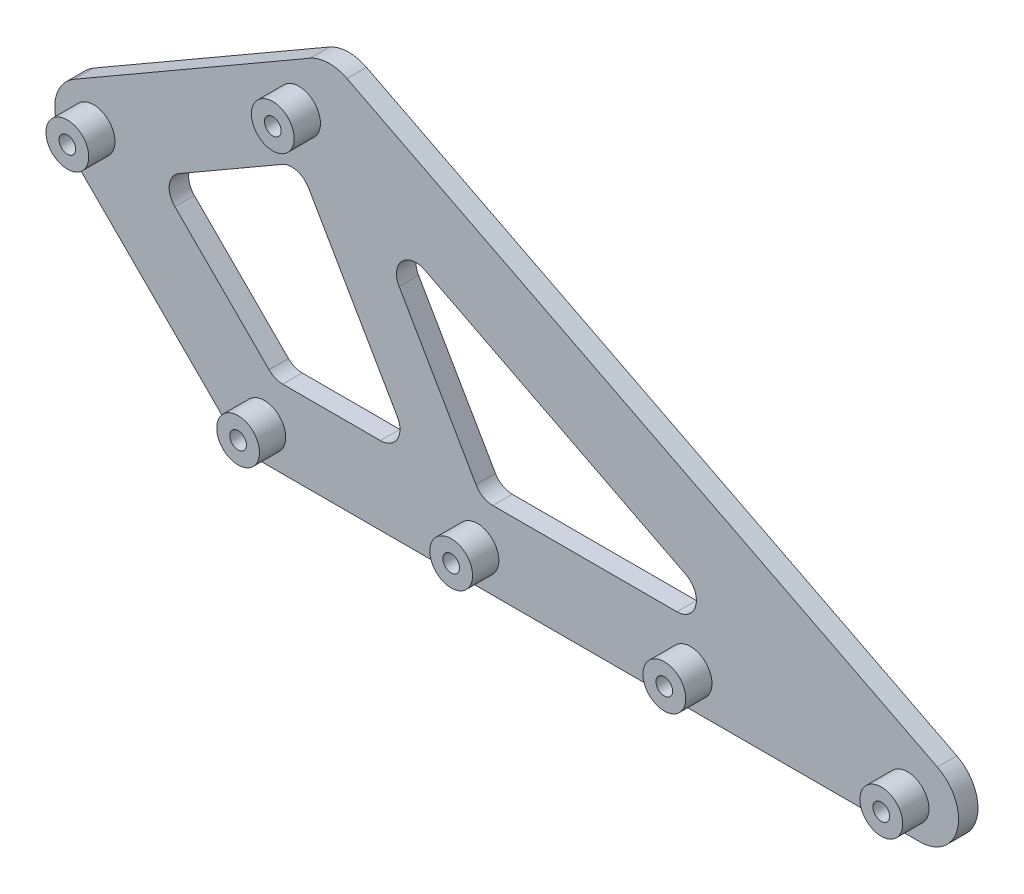
from build123d import *

# Parameters (mm, degrees)
BOSS_EXTRUDE1_DEPTH = 5
BOSS_EXTRUDE2_DEPTH = 5
FILLET1_R           = 5
SKETCH3_R           = 5.5
SKETCH3_R_2         = 2.15
BOSS_EXTRUDE3_DEPTH = 6.75
SKETCH4_R           = 2.15
CUT_EXTRUDE1_DEPTH  = 6


with BuildPart() as part:
    # Sketch1 → Boss-Extrude1 (new body)
    with BuildSketch(Plane.XY):
        with BuildLine():
            Line((-35.355339059, 49.497474683), (-26.140144074, 40.282279698))
            Line((-26.140144074, 40.282279698), (18.49094778, 66.050052594))
            Line((18.49094778, 66.050052594), (13.651828996, 68.518195913))
            ThreePointArc((13.651828996, 68.518195913), (8.198744915, 77.166678081), (13.195371394, 86.086660909))
            Line((13.195371394, 86.086660909), (-47.426406871, 51.086660909))
            ThreePointArc((-47.426406871, 51.086660909), (-41.121144949, 52.340855485), (-35.355339059, 49.497474683))
        make_face()
        with BuildLine():
            Line((18.49094778, 66.050052594), (128.384429361, 10))
            Line((128.384429361, 10), (170, 10))
            ThreePointArc((170, 10), (172.336438573, 9.723222449), (174.543542397, 8.908210959))
            Line((174.543542397, 8.908210959), (22.738913791, 86.33461783))
            ThreePointArc((22.738913791, 86.33461783), (28.191997872, 77.686135661), (23.195371394, 68.766152833))
            Line((23.195371394, 68.766152833), (18.49094778, 66.050052594))
        make_face()
        with BuildLine():
            Line((128.384429361, 10), (4.142135624, 10))
            Line((4.142135624, 10), (7.071067812, 7.071067812))
            ThreePointArc((7.071067812, 7.071067812), (9.238795325, -3.826834324), (0, -10))
            Line((0, -10), (170, -10))
            ThreePointArc((170, -10), (167.663561427, -9.723222449), (165.456457603, -8.908210959))
            Line((165.456457603, -8.908210959), (128.384429361, 10))
        make_face()
        with BuildLine():
            ThreePointArc((-7.071067812, -7.071067812), (-9.238795325, 3.826834324), (0, 10))
            Line((0, 10), (4.142135624, 10))
            Line((4.142135624, 10), (-26.140144074, 40.282279698))
            Line((-26.140144074, 40.282279698), (-37.426406871, 33.766152833))
            ThreePointArc((-37.426406871, 33.766152833), (-43.731668793, 32.511958257), (-49.497474683, 35.355339059))
            Line((-49.497474683, 35.355339059), (-7.071067812, -7.071067812))
        make_face()
        with BuildLine():
            Line((170, 10), (128.384429361, 10))
            Line((128.384429361, 10), (165.456457603, -8.908210959))
            ThreePointArc((165.456457603, -8.908210959), (167.663561427, -9.723222449), (170, -10))
            ThreePointArc((170, -10), (179.723222449, -2.336438573), (174.543542397, 8.908210959))
            ThreePointArc((174.543542397, 8.908210959), (172.336438573, 9.723222449), (170, 10))
        make_face()
        with BuildLine():
            Line((13.651828996, 68.518195913), (18.49094778, 66.050052594))
            Line((18.49094778, 66.050052594), (23.195371394, 68.766152833))
            ThreePointArc((23.195371394, 68.766152833), (28.191997872, 77.686135661), (22.738913791, 86.33461783))
            ThreePointArc((22.738913791, 86.33461783), (17.935642604, 87.42303335), (13.195371394, 86.086660909))
            ThreePointArc((13.195371394, 86.086660909), (8.198744915, 77.166678081), (13.651828996, 68.518195913))
        make_face()
        with BuildLine():
            Line((-37.426406871, 33.766152833), (-26.140144074, 40.282279698))
            Line((-26.140144074, 40.282279698), (-35.355339059, 49.497474683))
            ThreePointArc((-35.355339059, 49.497474683), (-41.121144949, 52.340855485), (-47.426406871, 51.086660909))
            ThreePointArc((-47.426406871, 51.086660909), (-52.340855485, 43.731668793), (-49.497474683, 35.355339059))
            ThreePointArc((-49.497474683, 35.355339059), (-43.731668793, 32.511958257), (-37.426406871, 33.766152833))
        make_face()
        with BuildLine():
            Line((4.142135624, 10), (0, 10))
            ThreePointArc((0, 10), (-9.238795325, 3.826834324), (-7.071067812, -7.071067812))
            ThreePointArc((-7.071067812, -7.071067812), (-3.826834324, -9.238795325), (0, -10))
            ThreePointArc((0, -10), (9.238795325, -3.826834324), (7.071067812, 7.071067812))
            Line((7.071067812, 7.071067812), (4.142135624, 10))
        make_face()
    extrude(amount=BOSS_EXTRUDE1_DEPTH)

    # Sketch2 → Boss-Extrude2 (add, through all)
    with BuildSketch(Plane.XY.offset(5)):
        Polygon((18.49094778, 66.050052594), (10.366771374, 61.359557158), (40.019225525, 10), (57.3397336, 10), (27.687279449, 61.359557158), align=None)
    extrude(amount=-BOSS_EXTRUDE2_DEPTH)

    # Fillet1
    fillet1_edges = [part.edges().sort_by_distance(p)[0] for p in [
        (-26.140144074, 40.282279698, 2.5),
        (4.142135624, 10, 2.5),
        (128.384429361, 10, 2.5),
        (27.687279449, 61.359557158, 2.5),
        (57.3397336, 10, 2.5),
        (40.019225525, 10, 2.5),
        (10.366771374, 61.359557158, 2.5),
    ]]
    fillet(fillet1_edges, radius=FILLET1_R)

    # Sketch3 → Boss-Extrude3 (add)
    with BuildSketch(Plane.XY.offset(5)):
        with Locations((-42.426406871, 42.426406871)):
            Circle(SKETCH3_R)
        with Locations((-42.426406871, 42.426406871)):
            Circle(SKETCH3_R_2, mode=Mode.SUBTRACT)
        with Locations((1.48492424, -1.48492424)):
            Circle(SKETCH3_R)
        with Locations((1.48492424, -1.48492424)):
            Circle(SKETCH3_R_2, mode=Mode.SUBTRACT)
        with Locations((56.28492424, -1.48492424)):
            Circle(SKETCH3_R)
        with Locations((56.28492424, -1.48492424)):
            Circle(SKETCH3_R_2, mode=Mode.SUBTRACT)
        with Locations((111.08492424, -1.48492424)):
            Circle(SKETCH3_R)
        with Locations((111.08492424, -1.48492424)):
            Circle(SKETCH3_R_2, mode=Mode.SUBTRACT)
        with Locations((166.88492424, -1.48492424)):
            Circle(SKETCH3_R)
        with Locations((166.88492424, -1.48492424)):
            Circle(SKETCH3_R_2, mode=Mode.SUBTRACT)
        with Locations((10.40114276, 72.926406871)):
            Circle(SKETCH3_R)
        with Locations((10.40114276, 72.926406871)):
            Circle(SKETCH3_R_2, mode=Mode.SUBTRACT)
    extrude(amount=BOSS_EXTRUDE3_DEPTH)

    # Sketch4 → Cut-Extrude1 (cut, through all)
    with BuildSketch(Plane.XY.offset(5)):
        with Locations((-42.426406871, 42.426406871)):
            Circle(SKETCH4_R)
        with Locations((1.48492424, -1.48492424)):
            Circle(SKETCH4_R)
        with Locations((56.28492424, -1.48492424)):
            Circle(SKETCH4_R)
        with Locations((111.08492424, -1.48492424)):
            Circle(SKETCH4_R)
        with Locations((166.88492424, -1.48492424)):
            Circle(SKETCH4_R)
        with Locations((10.40114276, 72.926406871)):
            Circle(SKETCH4_R)
    extrude(amount=-CUT_EXTRUDE1_DEPTH, mode=Mode.SUBTRACT)


solid = part.part
